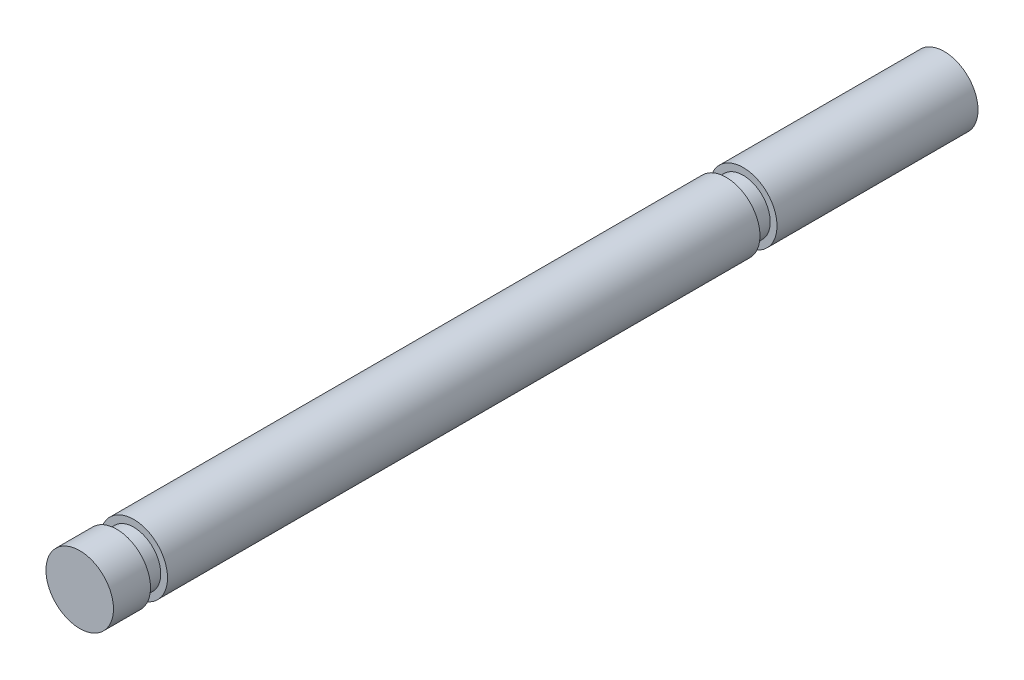
from build123d import *

# Parameters (mm, degrees)
SKETCH2_R           = 3.175
BOSS_EXTRUDE1_DEPTH = 81.28
SKETCH3_OUTSIDE_W   = 24.704
SKETCH3_OUTSIDE_H   = 24.704
SKETCH3_OUTSIDE_R   = 2.54
CUT_EXTRUDE1_DEPTH  = 1.6002
SKETCH4_OUTSIDE_W   = 24.704
SKETCH4_OUTSIDE_H   = 24.704
SKETCH4_OUTSIDE_R   = 2.54
CUT_EXTRUDE2_DEPTH  = 1.6002


with BuildPart() as part:
    # Sketch2 → Boss-Extrude1 (new body)
    with BuildSketch(Plane.XY):
        Circle(SKETCH2_R)
    extrude(amount=BOSS_EXTRUDE1_DEPTH)

    # Sketch3 outside → Cut-Extrude1 (cut)
    with BuildSketch(Plane(origin=(0, 0, 20.4978), x_dir=(-1, 0, 0), z_dir=(0, 0, -1))):
        Rectangle(SKETCH3_OUTSIDE_W, SKETCH3_OUTSIDE_H)
        Circle(SKETCH3_OUTSIDE_R, mode=Mode.SUBTRACT)
    extrude(amount=CUT_EXTRUDE1_DEPTH, mode=Mode.SUBTRACT)

    # Sketch4 outside → Cut-Extrude2 (cut)
    with BuildSketch(Plane.XY.offset(76.2)):
        Rectangle(SKETCH4_OUTSIDE_W, SKETCH4_OUTSIDE_H)
        Circle(SKETCH4_OUTSIDE_R, mode=Mode.SUBTRACT)
    extrude(amount=CUT_EXTRUDE2_DEPTH, mode=Mode.SUBTRACT)


solid = part.part
